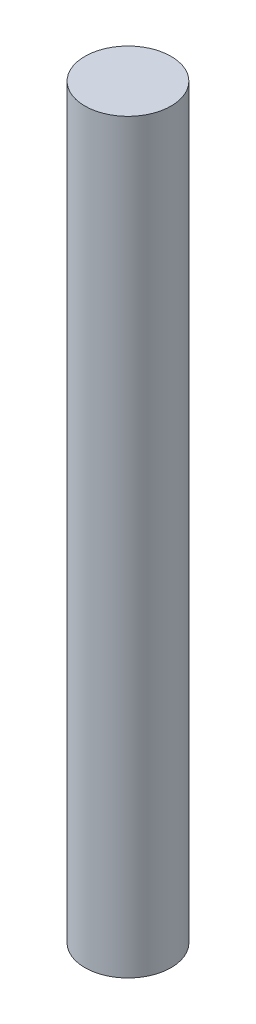
from build123d import *

# Parameters (mm, degrees)
SKETCH1_R           = 1.5875
BOSS_EXTRUDE1_DEPTH = 27.5


with BuildPart() as part:
    # Sketch1 → Boss-Extrude1 (new body)
    with BuildSketch(Plane(origin=(0, 0, 0), x_dir=(1, 0, 0), z_dir=(0, 1, 0))):
        Circle(SKETCH1_R)
    extrude(amount=BOSS_EXTRUDE1_DEPTH)


solid = part.part
